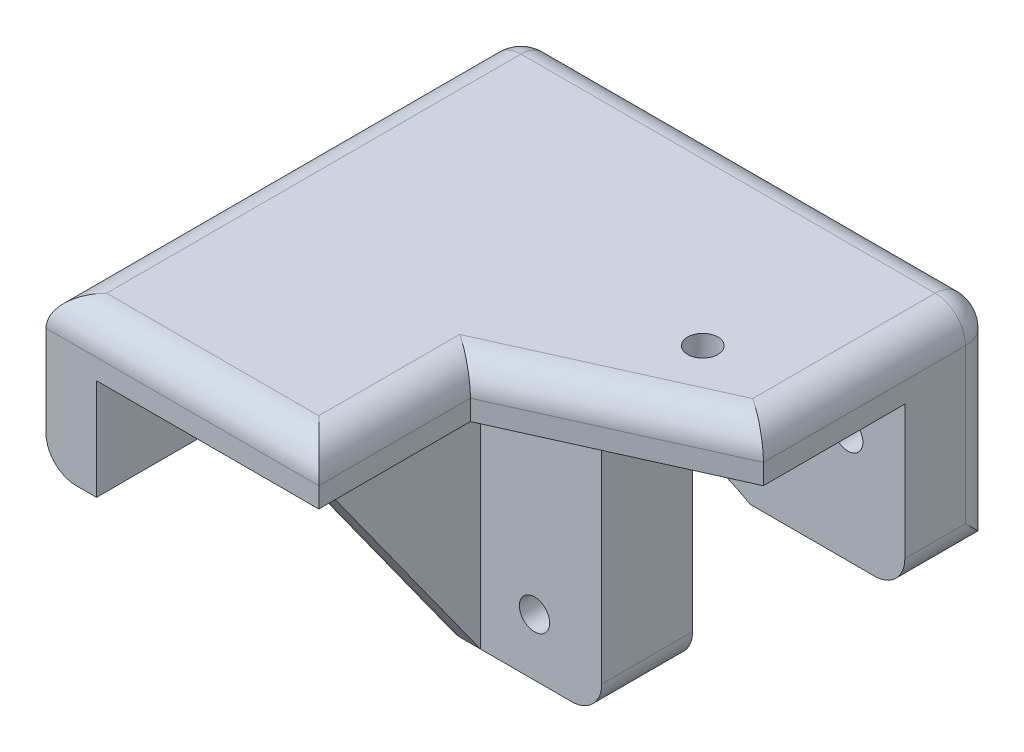
from build123d import *

# Parameters (mm, degrees)
BOSS_EXTRUDE1_DEPTH = 9
SKETCH3_R           = 1.5
CUT_EXTRUDE1_DEPTH  = 10
SKETCH4_W           = 5
SKETCH4_H           = 47
BOSS_EXTRUDE2_DEPTH = 38
CUT_EXTRUDE2_DEPTH  = 38
SKETCH6_W           = 42
SKETCH6_H           = 5
BOSS_EXTRUDE3_DEPTH = 38
SKETCH7_R           = 4
CUT_EXTRUDE3_DEPTH  = 5
CUT_EXTRUDE4_DEPTH  = 10
FILLET1_R           = 3
SKETCH9_R           = 1.5
CUT_EXTRUDE5_DEPTH  = 10
SKETCH10_R          = 3
CUT_EXTRUDE6_DEPTH  = 2


with BuildPart() as part:
    # Sketch2 → Boss-Extrude1 (new body)
    with BuildSketch(Plane.XY):
        with BuildLine():
            Line((0, 0), (0, 47))
            Line((0, 47), (47, 47))
            Line((47, 47), (47, 25.75))
            Line((47, 25.75), (31.68, 25.75))
            ThreePointArc((31.68, 25.75), (24.5283031, 28.175540714), (17, 27.58))
            Line((17, 27.58), (17, 0))
            Line((17, 0), (0, 0))
        make_face()
    extrude(amount=BOSS_EXTRUDE1_DEPTH)

    # Sketch3 → Cut-Extrude1 (cut)
    with BuildSketch(Plane.XY.offset(9)):
        with Locations((10.35, 5.65)):
            Circle(SKETCH3_R)
        with Locations((10.35, 36.65)):
            Circle(SKETCH3_R)
        with Locations((41.35, 36.65)):
            Circle(SKETCH3_R)
    extrude(amount=-CUT_EXTRUDE1_DEPTH, mode=Mode.SUBTRACT)

    # Sketch4 → Boss-Extrude2 (add)
    with BuildSketch(Plane.XY.offset(9)):
        with Locations((2.5, 23.5)):
            Rectangle(SKETCH4_W, SKETCH4_H)
    extrude(amount=BOSS_EXTRUDE2_DEPTH)

    # Sketch5 → Cut-Extrude2 (cut)
    with BuildSketch(Plane.ZY):
        Polygon((47, 32), (32, 32), (9, 0), (47, 0), align=None)
    extrude(amount=-CUT_EXTRUDE2_DEPTH, mode=Mode.SUBTRACT)

    # Sketch6 → Boss-Extrude3 (add)
    with BuildSketch(Plane.XY.offset(9)):
        with Locations((26, 44.5)):
            Rectangle(SKETCH6_W, SKETCH6_H)
    extrude(amount=BOSS_EXTRUDE3_DEPTH)

    # Sketch7 → Cut-Extrude3 (cut)
    with BuildSketch(Plane(origin=(0, 0, 0), x_dir=(-1, 0, 0), z_dir=(0, 0, -1))):
        with Locations((-10, 20.85)):
            Circle(SKETCH7_R)
    extrude(amount=-CUT_EXTRUDE3_DEPTH, mode=Mode.SUBTRACT)

    # Sketch8 → Cut-Extrude4 (cut)
    with BuildSketch(Plane(origin=(0, 42, 0), x_dir=(-1, 0, 0), z_dir=(0, -1, 0))):
        Polygon((-27, -32), (-47, -23), (-47, -47), (-27, -47), align=None)
    extrude(amount=-CUT_EXTRUDE4_DEPTH, mode=Mode.SUBTRACT)

    # Fillet1
    fillet1_edges = [part.edges().sort_by_distance(p)[0] for p in [
        (0, 47, 23.5),
        (47, 25.75, 4.5),
        (17, 27.58, 4.5),
        (17, 0, 4.5),
        (0, 0, 4.5),
        (0, 32, 39.5),
        (0, 16, 20.5),
        (0, 23.5, 0),
        (23.5, 47, 0),
        (47, 36.375, 0),
        (13.5, 47, 47),
        (47, 47, 11.5),
        (27, 47, 39.5),
        (37, 47, 27.5),
    ]]
    fillet(fillet1_edges, radius=FILLET1_R)

    # Sketch9 → Cut-Extrude5 (cut)
    with BuildSketch(Plane(origin=(0, 42, 0), x_dir=(-1, 0, 0), z_dir=(0, -1, 0))):
        with Locations((-37, -19)):
            Circle(SKETCH9_R)
    extrude(amount=-CUT_EXTRUDE5_DEPTH, mode=Mode.SUBTRACT)

    # Sketch10 → Cut-Extrude6 (cut)
    with BuildSketch(Plane(origin=(0, 42, 0), x_dir=(-1, 0, 0), z_dir=(0, -1, 0))):
        with Locations((-37, -19)):
            Circle(SKETCH10_R)
    extrude(amount=-CUT_EXTRUDE6_DEPTH, mode=Mode.SUBTRACT)


solid = part.part
